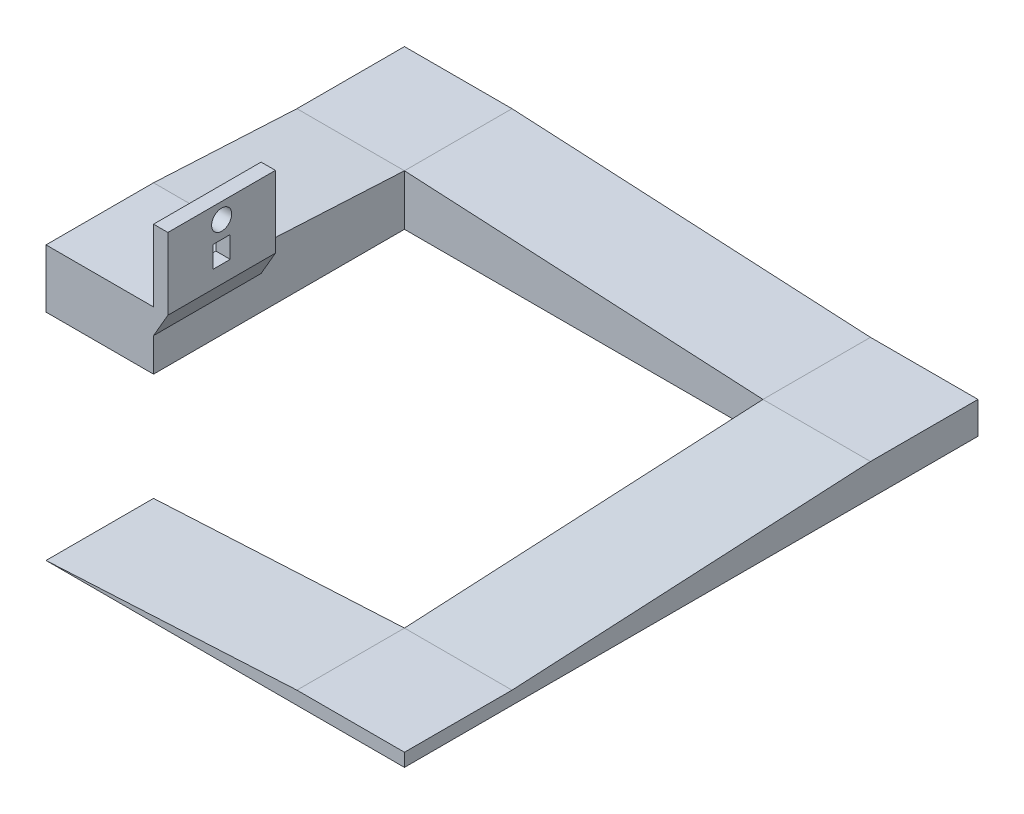
from build123d import *

# Parameters (mm, degrees)
BOSS_EXTRUDE1_DEPTH  = 19.05
BOSS_EXTRUDE2_DEPTH  = 19.05
BOSS_EXTRUDE3_DEPTH  = 19.05
BOSS_EXTRUDE4_DEPTH  = 19.05
BOSS_EXTRUDE13_DEPTH = 19.05
CUT_EXTRUDE1_REACH   = 84.55
SKETCH14_R           = 1.778
SKETCH14_W           = 3.048
SKETCH14_H           = 3.81


with BuildPart() as part:
    # Sketch1 → Boss-Extrude1 (new body)
    with BuildSketch(Plane.XY):
        Polygon((0, 0), (44.45, 2.329525789), (63.5, 2.329525789), (63.5, 0), align=None)
    extrude(amount=BOSS_EXTRUDE1_DEPTH)

    # Sketch2 → Boss-Extrude2 (add)
    with BuildSketch(Plane(origin=(63.5, 0, 0), x_dir=(0, 0, -1), z_dir=(1, 0, 0))):
        Polygon((0, 0), (0, 2.329525789), (63.5, 5.657419774), (82.55, 5.657419774), (82.55, 0), align=None)
    extrude(amount=-BOSS_EXTRUDE2_DEPTH)

    # Sketch3 → Boss-Extrude3 (add)
    with BuildSketch(Plane(origin=(0, 0, -82.55), x_dir=(-1, 0, 0), z_dir=(0, 0, -1))):
        Polygon((-44.45, 0), (-44.45, 5.657419774), (19.05, 8.985313758), (38.1, 8.985313758), (38.1, 0), align=None)
    extrude(amount=-BOSS_EXTRUDE3_DEPTH)

    # Sketch4 → Boss-Extrude4 (add)
    with BuildSketch(Plane.ZY.offset(38.1)):
        Polygon((-63.5, 8.985313758), (-38.1, 10.316471352), (-19.05, 10.316471352), (-19.05, 0), (-63.5, 0), align=None)
    extrude(amount=-BOSS_EXTRUDE4_DEPTH)

    # Sketch13 → Boss-Extrude13 (add)
    with BuildSketch(Plane.XY.offset(-19.05)):
        Polygon((-19.05, 5.917062301), (-19.05, 23.016471352), (-16.51, 23.016471352), (-16.51, 10.316471352), align=None)
    extrude(amount=-BOSS_EXTRUDE13_DEPTH)

    # Sketch14 → Cut-Extrude1 (cut, up to next)
    with BuildSketch(Plane.ZY.offset(19.05), mode=Mode.PRIVATE) as cut_extrude1_sk1:
        with Locations((-28.575, 20.222471352)):
            Circle(SKETCH14_R)
    cut_extrude1_tool1 = extrude(cut_extrude1_sk1.sketch, amount=-CUT_EXTRUDE1_REACH, mode=Mode.PRIVATE) & part.part
    add(cut_extrude1_tool1.solids().sort_by_distance((-19.05, 20.222471, -28.575))[0], mode=Mode.SUBTRACT)
    # Sketch14 → Cut-Extrude1 (cut, up to next)
    with BuildSketch(Plane.ZY.offset(19.05), mode=Mode.PRIVATE) as cut_extrude1_sk2:
        with Locations((-28.575, 15.269471352)):
            Rectangle(SKETCH14_W, SKETCH14_H)
    cut_extrude1_tool2 = extrude(cut_extrude1_sk2.sketch, amount=-CUT_EXTRUDE1_REACH, mode=Mode.PRIVATE) & part.part
    add(cut_extrude1_tool2.solids().sort_by_distance((-19.05, 15.269471, -28.575))[0], mode=Mode.SUBTRACT)


solid = part.part
